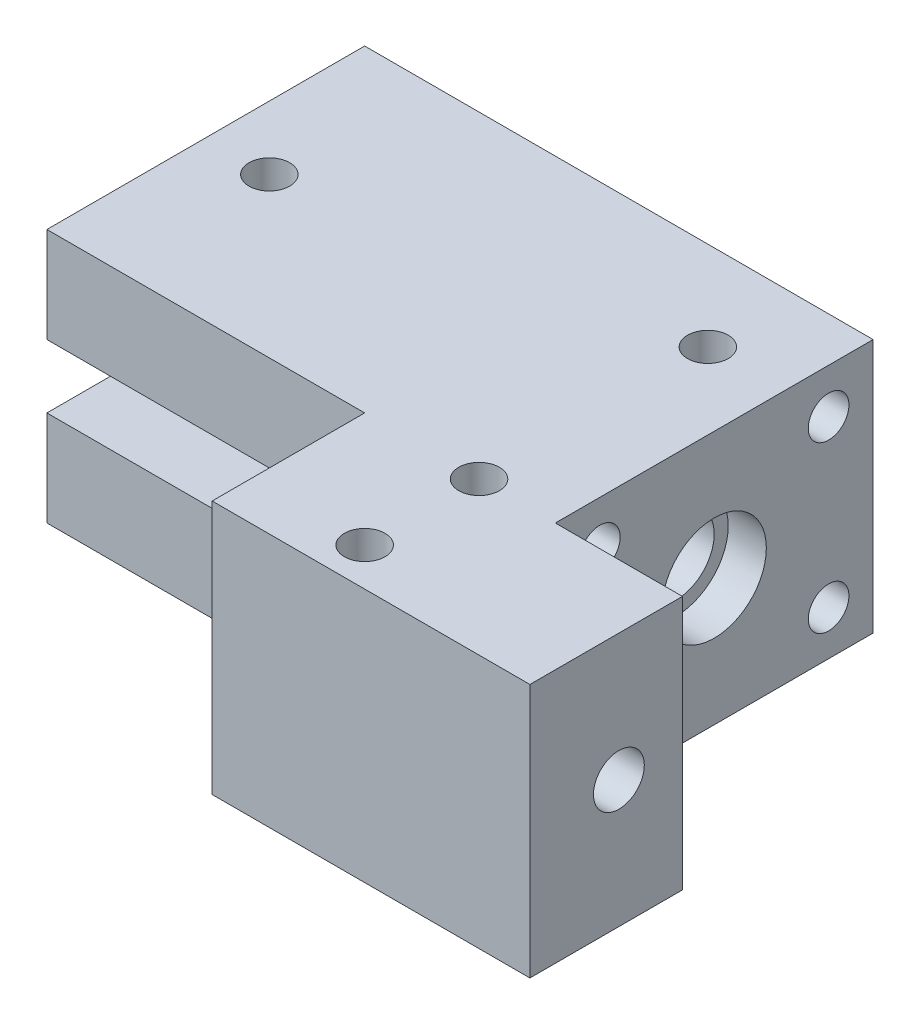
from build123d import *

# Parameters (mm, degrees)
SKETCH_1_W          = 40
SKETCH_1_H          = 25
EXTRUDE_1_DEPTH     = 20
SKETCH_3_R          = 3
CUT_EXTRUDE_2_DEPTH = 41
SKETCH_2_R          = 4.1
CUT_EXTRUDE_1_DEPTH = 26
SKETCH_4_W          = 25
SKETCH_4_H          = 5
CUT_EXTRUDE_3_DEPTH = 20
SKETCH_5_R          = 4.1
CUT_EXTRUDE_4_DEPTH = 3
SKETCH_6_R          = 1.6
CUT_EXTRUDE_5_DEPTH = 21
SKETCH_7_R          = 1.6
CUT_EXTRUDE_6_DEPTH = 41
SKETCH_8_W          = 25
SKETCH_8_H          = 20
EXTRUDE_2_DEPTH     = 12
SKETCH_9_R          = 1.6
CUT_EXTRUDE_7_DEPTH = 21.0000001
SKETCH_10_R         = 2
CUT_EXTRUDE_8_DEPTH = 26
SKETCH_12_R         = 5
CUT_EXTRUDE_9_DEPTH = 23


with BuildPart() as part:
    # Эскиз1 → Бобышка-Вытянуть1 (new body)
    with BuildSketch(Plane(origin=(0, 0, 0), x_dir=(1, 0, 0), z_dir=(0, 1, 0))):
        Rectangle(SKETCH_1_W, SKETCH_1_H)
    extrude(amount=EXTRUDE_1_DEPTH)

    # Эскиз3 → Вырез-Вытянуть2 (cut, through all)
    with BuildSketch(Plane.ZY.offset(20)):
        with Locations((0, 10)):
            Circle(SKETCH_3_R)
    extrude(amount=-CUT_EXTRUDE_2_DEPTH, mode=Mode.SUBTRACT)

    # Эскиз2 → Вырез-Вытянуть1 (cut)
    with BuildSketch(Plane.ZY.offset(20)):
        with Locations((0, 10)):
            Circle(SKETCH_2_R)
    extrude(amount=-CUT_EXTRUDE_1_DEPTH, mode=Mode.SUBTRACT)

    # Эскиз4 → Вырез-Вытянуть3 (cut)
    with BuildSketch(Plane(origin=(-20, 0, 0), x_dir=(0, 0, -1), z_dir=(1, 0, 0))):
        with Locations((0, 10)):
            Rectangle(SKETCH_4_W, SKETCH_4_H)
    extrude(amount=CUT_EXTRUDE_3_DEPTH, mode=Mode.SUBTRACT)

    # Эскиз5 → Вырез-Вытянуть4 (cut)
    with BuildSketch(Plane(origin=(20, 0, 0), x_dir=(0, 0, -1), z_dir=(1, 0, 0))):
        with Locations((0, 10)):
            Circle(SKETCH_5_R)
    extrude(amount=-CUT_EXTRUDE_4_DEPTH, mode=Mode.SUBTRACT)

    # Эскиз6 → Вырез-Вытянуть5 (cut, through all)
    with BuildSketch(Plane(origin=(0, 20, 0), x_dir=(1, 0, 0), z_dir=(0, 1, 0))):
        with Locations((-15, 0)):
            Circle(SKETCH_6_R)
    extrude(amount=-CUT_EXTRUDE_5_DEPTH, mode=Mode.SUBTRACT)

    # Эскиз7 → Вырез-Вытянуть6 (cut, through all)
    with BuildSketch(Plane.ZY.offset(20)):
        with Locations((-9, 16.5)):
            Circle(SKETCH_7_R)
        with Locations((9, 16.5)):
            Circle(SKETCH_7_R)
        with Locations((-9, 3.5)):
            Circle(SKETCH_7_R)
        with Locations((9, 3.5)):
            Circle(SKETCH_7_R)
    extrude(amount=-CUT_EXTRUDE_6_DEPTH, mode=Mode.SUBTRACT)

    # Эскиз8 → Бобышка-Вытянуть2 (add)
    with BuildSketch(Plane.XY.offset(12.5)):
        with Locations((17.5, 10)):
            Rectangle(SKETCH_8_W, SKETCH_8_H)
    extrude(amount=EXTRUDE_2_DEPTH)

    # Эскиз9 → Вырез-Вытянуть7 (cut, through all)
    with BuildSketch(Plane(origin=(0, 20, 0), x_dir=(1, 0, 0), z_dir=(0, 1, 0))):
        with Locations((14, -21.5)):
            Circle(SKETCH_9_R)
        with Locations((14, 5.5)):
            Circle(SKETCH_9_R)
        with Locations((14, -12.5)):
            Circle(SKETCH_9_R)
    extrude(amount=-CUT_EXTRUDE_7_DEPTH, mode=Mode.SUBTRACT)

    # Эскиз10 → Вырез-Вытянуть8 (cut, through all)
    with BuildSketch(Plane.ZY.offset(-5)):
        with Locations((17.5, 10)):
            Circle(SKETCH_10_R)
    extrude(amount=-CUT_EXTRUDE_8_DEPTH, mode=Mode.SUBTRACT)

    # Эскиз12 → Вырез-Вытянуть9 (cut)
    with BuildSketch(Plane.ZY.offset(20)):
        with Locations((0, 10)):
            Circle(SKETCH_12_R)
    extrude(amount=-CUT_EXTRUDE_9_DEPTH, mode=Mode.SUBTRACT)


solid = part.part
